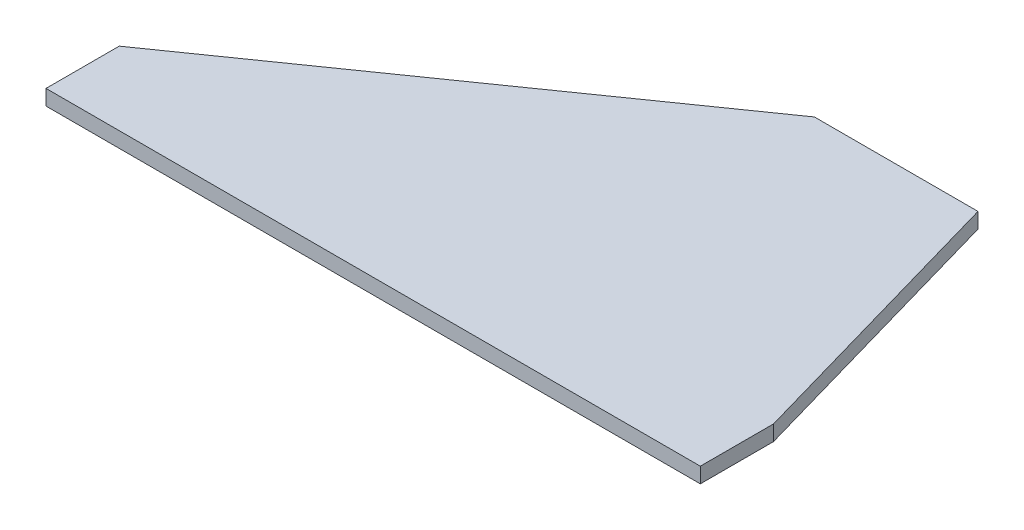
from build123d import *

# Parameters (mm, degrees)
BOSS_EXTRUDE1_DEPTH      = 2.38125
BOSS_EXTRUDE1_DEPTH_BACK = 2.38125


with BuildPart() as part:
    # Sketch1 → Boss-Extrude1 (new, two sides: drawn at the far end of the back side and taken through both)
    with BuildSketch(Plane(origin=(0, 0, 0), x_dir=(1, 0, 0), z_dir=(0, 1, 0)).offset(-BOSS_EXTRUDE1_DEPTH_BACK)):
        Polygon((0, 0), (0, 22.733), (127, 111.633), (177.8, 111.633), (203.2, 22.733), (203.2, 0), align=None)
    extrude(amount=BOSS_EXTRUDE1_DEPTH + BOSS_EXTRUDE1_DEPTH_BACK)


solid = part.part
